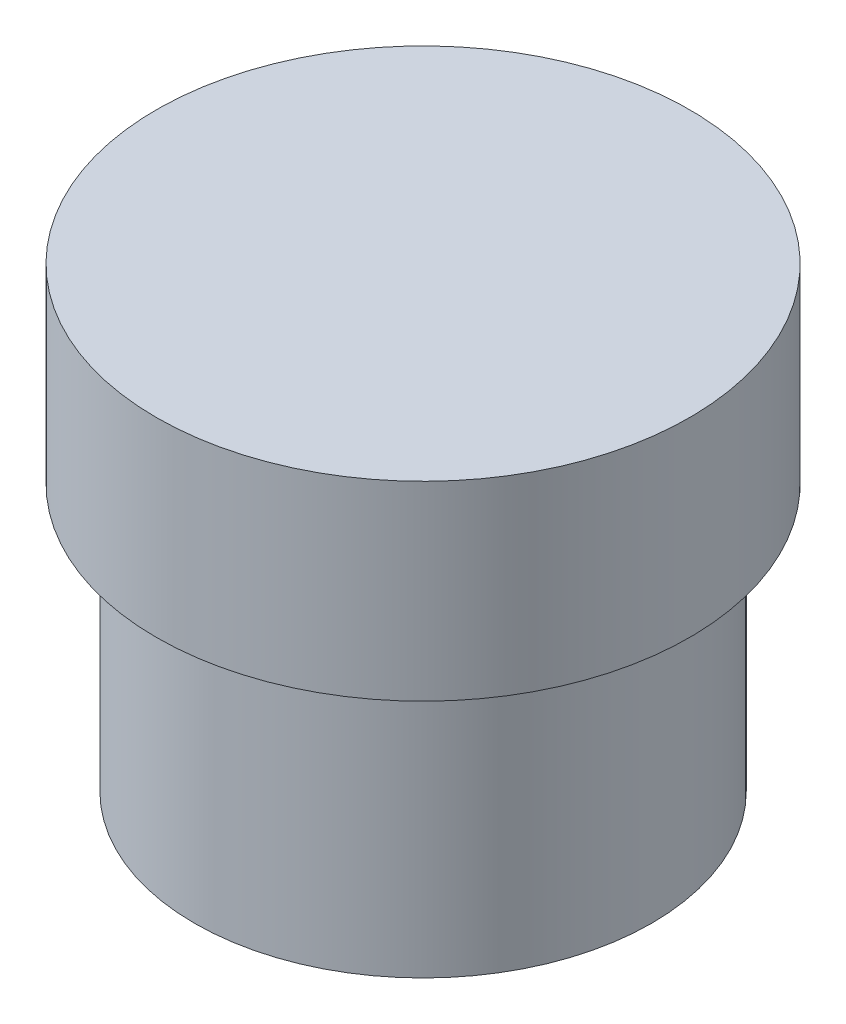
from build123d import *

# Parameters (mm, degrees)
SKETCH_1_R      = 7
EXTRUDE_2_DEPTH = 5
SKETCH_3_R      = 6
EXTRUDE_3_DEPTH = 7


with BuildPart() as part:
    # 草图1 → 凸台-拉伸2 (new body)
    with BuildSketch(Plane(origin=(0, 0, 0), x_dir=(1, 0, 0), z_dir=(0, 1, 0))):
        Circle(SKETCH_1_R)
    extrude(amount=-EXTRUDE_2_DEPTH)

    # 草图3 → 凸台-拉伸3 (add)
    with BuildSketch(Plane(origin=(0, -5, 0), x_dir=(-1, 0, 0), z_dir=(0, -1, 0))):
        Circle(SKETCH_3_R)
    extrude(amount=EXTRUDE_3_DEPTH)


solid = part.part
